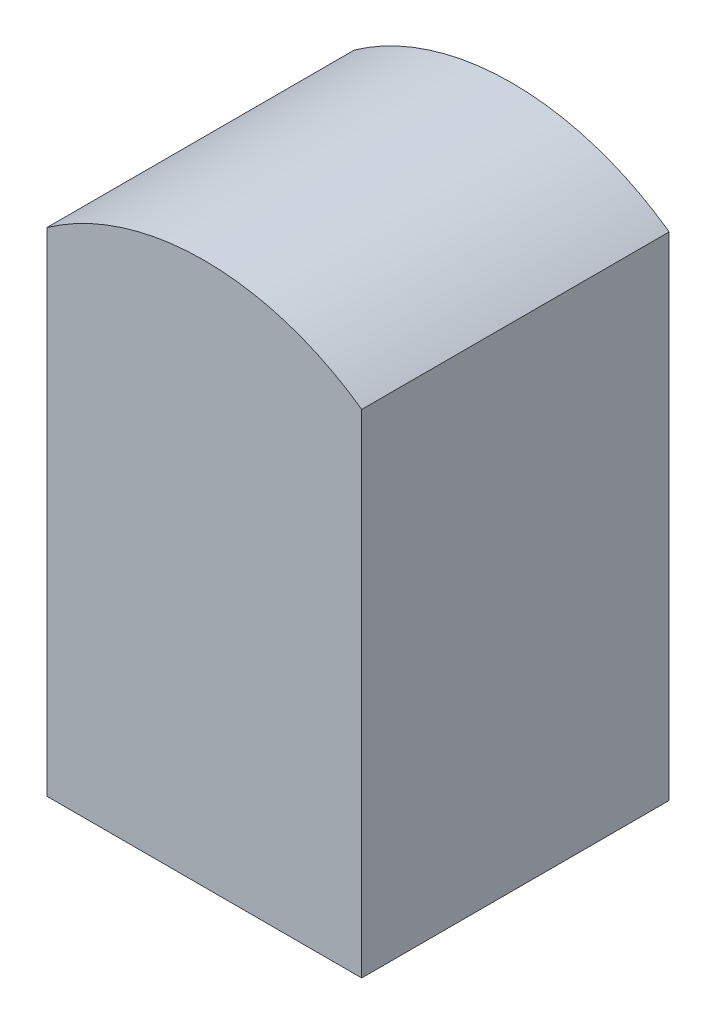
from build123d import *

# Parameters (mm, degrees)
EXTRUDE_1_DEPTH = 83


with BuildPart() as part:
    # 草图1 → 凸台-拉伸1 (new body)
    with BuildSketch(Plane.XY):
        with BuildLine():
            ThreePointArc((42.5, 59.659974019), (22.309968658, 69.769820112), (0, 73.25))
            ThreePointArc((0, 73.25), (-22.309968658, 69.769820112), (-42.5, 59.659974019))
            Line((-42.5, 59.659974019), (-42.5, -59.659974019))
            ThreePointArc((-42.5, -59.659974019), (-22.309968513, -69.769820159), (3.06e-07, -73.25))
            ThreePointArc((3.06e-07, -73.25), (22.309968804, -69.769820065), (42.5, -59.659974019))
            Line((42.5, -59.659974019), (42.5, 59.659974019))
        make_face()
        with BuildLine():
            Line((42.5, -73.25), (42.5, -59.659974019))
            ThreePointArc((42.5, -59.659974019), (22.309968804, -69.769820065), (3.06e-07, -73.25))
            Line((3.06e-07, -73.25), (42.5, -73.25))
        make_face()
        with BuildLine():
            ThreePointArc((3.06e-07, -73.25), (-22.309968513, -69.769820159), (-42.5, -59.659974019))
            Line((-42.5, -59.659974019), (-42.5, -73.25))
            Line((-42.5, -73.25), (3.06e-07, -73.25))
        make_face()
    extrude(amount=EXTRUDE_1_DEPTH)


solid = part.part
